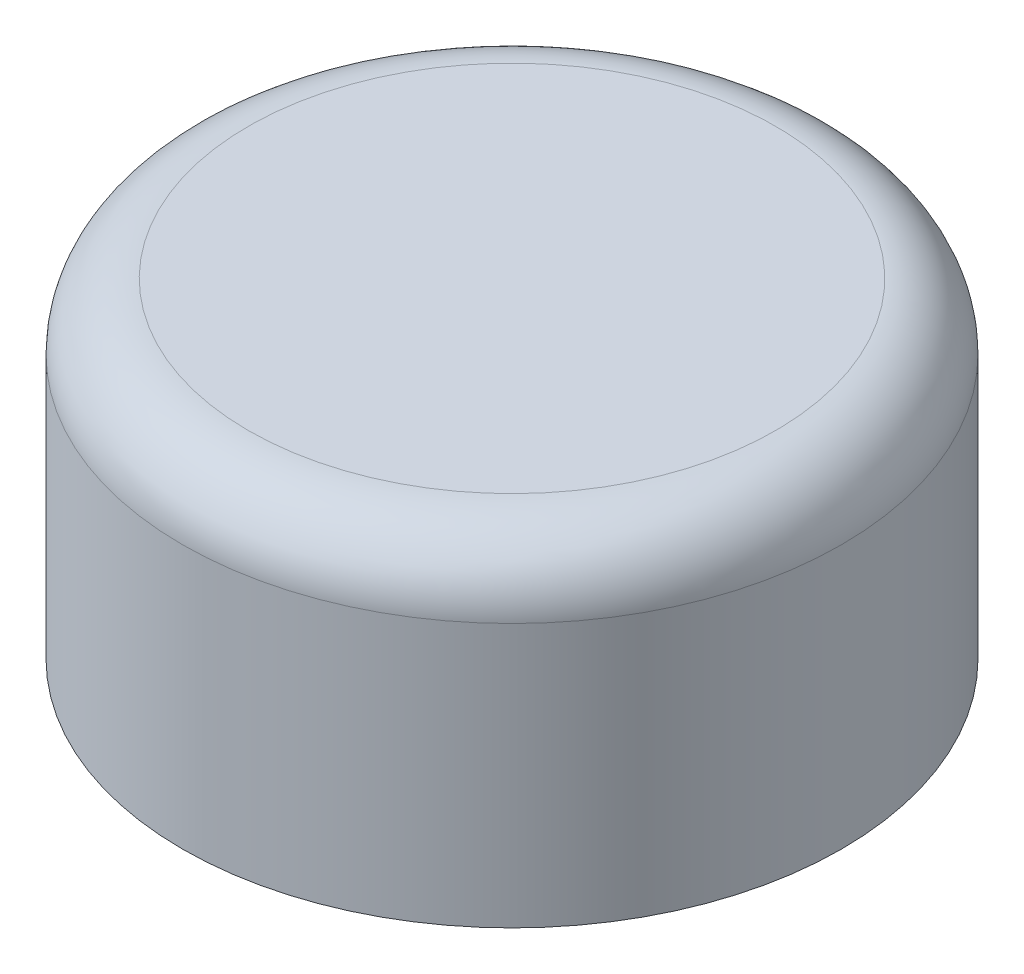
from build123d import *

# Parameters (mm, degrees)
SKETCH1_R           = 5
BOSS_EXTRUDE1_DEPTH = 5
FILLET1_R           = 1
SKETCH2_R           = 3.7
CUT_EXTRUDE1_DEPTH  = 2


with BuildPart() as part:
    # Sketch1 → Boss-Extrude1 (new body)
    with BuildSketch(Plane(origin=(0, 0, 0), x_dir=(1, 0, 0), z_dir=(0, 1, 0))):
        Circle(SKETCH1_R)
    extrude(amount=BOSS_EXTRUDE1_DEPTH)

    # Fillet1
    fillet1_edges = [part.edges().sort_by_distance(p)[0] for p in [
        (-5, 5, 0),
    ]]
    fillet(fillet1_edges, radius=FILLET1_R)

    # Sketch2 → Cut-Extrude1 (cut)
    with BuildSketch(Plane.XZ):
        Circle(SKETCH2_R)
    extrude(amount=-CUT_EXTRUDE1_DEPTH, mode=Mode.SUBTRACT)


solid = part.part
